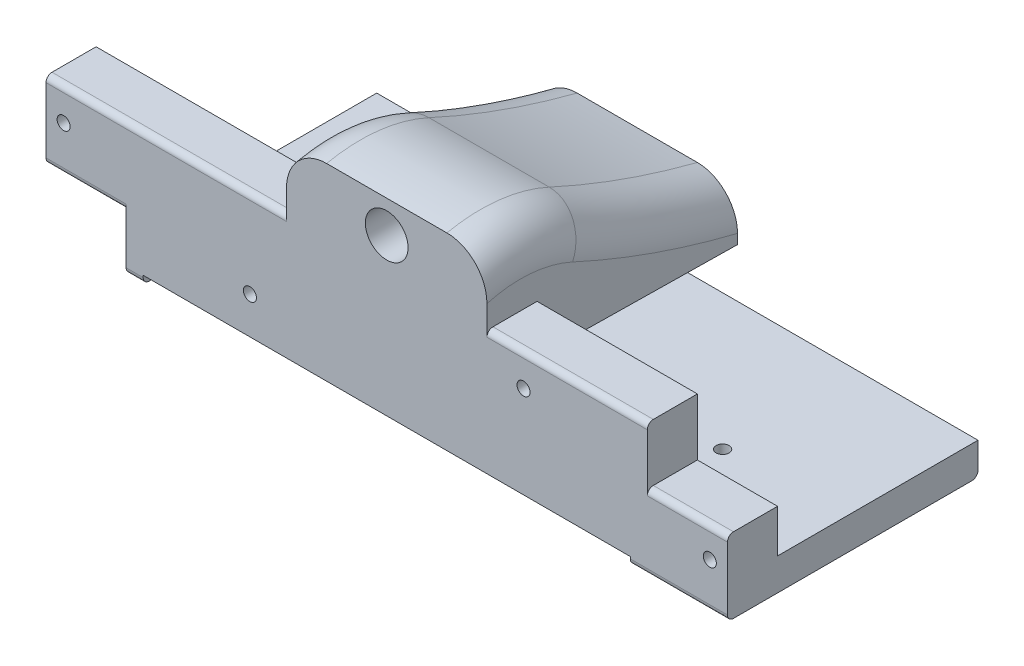
from build123d import *

# Parameters (mm, degrees)
SKETCH1_W           = 86.36
SKETCH1_H           = 31.75
BOSS_EXTRUDE1_DEPTH = 16.764
SKETCH2_W           = 25.4
SKETCH2_H           = 6.35
CUT_EXTRUDE1_DEPTH  = 86.36
SKETCH3_W           = 25.4
SKETCH3_H           = 6.35
CUT_EXTRUDE2_DEPTH  = 50.8
SKETCH5_W           = 61.722
SKETCH5_H           = 17.1196
CUT_EXTRUDE3_DEPTH  = 1.016
SKETCH5_3_R         = 0.81915
CUT_EXTRUDE4_DEPTH  = 49.964882528
CUT_EXTRUDE8_REACH  = 58.157
SKETCH6_W           = 10.16
SKETCH6_H           = 5.08
SKETCH6_R           = 0.8255
SKETCH6_H_2         = 6.985
SKETCH6_H_3         = 2.1717
SKETCH7_W           = 25.4
SKETCH7_H           = 7.62
BOSS_EXTRUDE2_DEPTH = 25.4
CUT_EXTRUDE9_DEPTH  = 25.4
FILLET1_R           = 0.381
SKETCH11_W          = 25.4
SKETCH11_H          = 8.89
BOSS_EXTRUDE5_DEPTH = 31.75
FILLET2_R           = 0.762
CUT_EXTRUDE10_DEPTH = 25.4
FILLET4_R           = 5.08
SKETCH10_R          = 2.7051
CUT_EXTRUDE11_DEPTH = 8.001


with BuildPart() as part:
    # Sketch1 → Boss-Extrude1 (new body)
    with BuildSketch(Plane(origin=(0, 0, 0), x_dir=(1, 0, 0), z_dir=(0, 1, 0))):
        Rectangle(SKETCH1_W, SKETCH1_H)
    extrude(amount=BOSS_EXTRUDE1_DEPTH)

    # Sketch2 → Cut-Extrude1 (cut)
    with BuildSketch(Plane.ZY.offset(43.18)):
        with Locations((-3.175, 7.239)):
            Rectangle(SKETCH2_W, SKETCH2_H)
    extrude(amount=-CUT_EXTRUDE1_DEPTH, mode=Mode.SUBTRACT)

    # Sketch3 → Cut-Extrude2 (cut)
    with BuildSketch(Plane.ZY.offset(43.18)):
        with Locations((-3.175, 13.589)):
            Rectangle(SKETCH3_W, SKETCH3_H)
    cut_extrude2 = extrude(amount=-CUT_EXTRUDE2_DEPTH, mode=Mode.SUBTRACT)

    # Mirror1: Cut-Extrude2 across plane
    add(cut_extrude2.mirror(Plane(origin=(0, 0, 0), x_dir=(0, 0, 1), z_dir=(1, 0, 0))), mode=Mode.SUBTRACT)

    # Sketch5 → Cut-Extrude3 (cut)
    with BuildSketch(Plane.XZ):
        with Locations((0, 7.3152)):
            Rectangle(SKETCH5_W, SKETCH5_H)
    extrude(amount=-CUT_EXTRUDE3_DEPTH, mode=Mode.SUBTRACT)

    # Sketch5_3 → Cut-Extrude4 (cut, through all)
    with BuildSketch(Plane.XZ):
        with Locations(Location((-27.9908, 1.2954, 0), (0, 0, 270))):
            Circle(SKETCH5_3_R)
        with Locations(Location((27.9908, 1.2954, 0), (0, 0, 270))):
            Circle(SKETCH5_3_R)
    extrude(amount=-CUT_EXTRUDE4_DEPTH, mode=Mode.SUBTRACT)

    # Cut-Extrude8: up to this face of the body (flat: up to its plane)
    cut_extrude8_end = Plane(part.part.faces().sort_by_distance((0, 2.032, -15.875))[0])
    # Sketch6 → Cut-Extrude8 (cut, up to the picked face)
    with BuildSketch(Plane.XY.offset(15.875), mode=Mode.PRIVATE) as cut_extrude8_sk1:
        with Locations((38.1, 12.0523)):
            Rectangle(SKETCH6_W, SKETCH6_H)
        with Locations((40.9448, 12.6873)):
            Circle(SKETCH6_R, mode=Mode.SUBTRACT)
    cut_extrude8_tool1 = split(extrude(cut_extrude8_sk1.sketch, amount=-CUT_EXTRUDE8_REACH, mode=Mode.PRIVATE), bisect_by=cut_extrude8_end, keep=Keep.BOTH, mode=Mode.PRIVATE)
    # Sketch6 → Cut-Extrude8 (cut, up to the picked face)
    with BuildSketch(Plane.XY.offset(15.875), mode=Mode.PRIVATE) as cut_extrude8_sk2:
        with Locations((40.9448, 12.6873)):
            Circle(SKETCH6_R)
    cut_extrude8_tool2 = split(extrude(cut_extrude8_sk2.sketch, amount=-CUT_EXTRUDE8_REACH, mode=Mode.PRIVATE), bisect_by=cut_extrude8_end, keep=Keep.BOTH, mode=Mode.PRIVATE)
    # Sketch6 → Cut-Extrude8 (cut, up to the picked face)
    with BuildSketch(Plane.XY.offset(15.875), mode=Mode.PRIVATE) as cut_extrude8_sk3:
        with Locations((17.3355, 12.6873)):
            Circle(SKETCH6_R)
    cut_extrude8_tool3 = split(extrude(cut_extrude8_sk3.sketch, amount=-CUT_EXTRUDE8_REACH, mode=Mode.PRIVATE), bisect_by=cut_extrude8_end, keep=Keep.BOTH, mode=Mode.PRIVATE)
    # Sketch6 → Cut-Extrude8 (cut, up to the picked face)
    with BuildSketch(Plane.XY.offset(15.875), mode=Mode.PRIVATE) as cut_extrude8_sk4:
        with Locations((40.9448, 5.715)):
            Circle(SKETCH6_R)
    cut_extrude8_tool4 = split(extrude(cut_extrude8_sk4.sketch, amount=-CUT_EXTRUDE8_REACH, mode=Mode.PRIVATE), bisect_by=cut_extrude8_end, keep=Keep.BOTH, mode=Mode.PRIVATE)
    # Sketch6 → Cut-Extrude8 (cut, up to the picked face)
    with BuildSketch(Plane.XY.offset(15.875), mode=Mode.PRIVATE) as cut_extrude8_sk5:
        with Locations((-38.1, 3.4925)):
            Rectangle(SKETCH6_W, SKETCH6_H_2)
        with Locations((-40.9448, 5.715)):
            Circle(SKETCH6_R, mode=Mode.SUBTRACT)
    cut_extrude8_tool5 = split(extrude(cut_extrude8_sk5.sketch, amount=-CUT_EXTRUDE8_REACH, mode=Mode.PRIVATE), bisect_by=cut_extrude8_end, keep=Keep.BOTH, mode=Mode.PRIVATE)
    # Sketch6 → Cut-Extrude8 (cut, up to the picked face)
    with BuildSketch(Plane.XY.offset(15.875), mode=Mode.PRIVATE) as cut_extrude8_sk6:
        with Locations((-40.9448, 5.715)):
            Circle(SKETCH6_R)
    cut_extrude8_tool6 = split(extrude(cut_extrude8_sk6.sketch, amount=-CUT_EXTRUDE8_REACH, mode=Mode.PRIVATE), bisect_by=cut_extrude8_end, keep=Keep.BOTH, mode=Mode.PRIVATE)
    # Sketch6 → Cut-Extrude8 (cut, up to the picked face)
    with BuildSketch(Plane.XY.offset(15.875), mode=Mode.PRIVATE) as cut_extrude8_sk7:
        with Locations((-17.3355, 5.715)):
            Circle(SKETCH6_R)
    cut_extrude8_tool7 = split(extrude(cut_extrude8_sk7.sketch, amount=-CUT_EXTRUDE8_REACH, mode=Mode.PRIVATE), bisect_by=cut_extrude8_end, keep=Keep.BOTH, mode=Mode.PRIVATE)
    # Sketch6 → Cut-Extrude8 (cut, up to the picked face)
    with BuildSketch(Plane.XY.offset(15.875), mode=Mode.PRIVATE) as cut_extrude8_sk8:
        with Locations((-40.9448, 12.6873)):
            Circle(SKETCH6_R)
    cut_extrude8_tool8 = split(extrude(cut_extrude8_sk8.sketch, amount=-CUT_EXTRUDE8_REACH, mode=Mode.PRIVATE), bisect_by=cut_extrude8_end, keep=Keep.BOTH, mode=Mode.PRIVATE)
    # Sketch6 → Cut-Extrude8 (cut, up to the picked face)
    with BuildSketch(Plane.XY.offset(15.875), mode=Mode.PRIVATE) as cut_extrude8_sk9:
        with Locations((38.1, 15.67815)):
            Rectangle(SKETCH6_W, SKETCH6_H_3)
    cut_extrude8_tool9 = split(extrude(cut_extrude8_sk9.sketch, amount=-CUT_EXTRUDE8_REACH, mode=Mode.PRIVATE), bisect_by=cut_extrude8_end, keep=Keep.BOTH, mode=Mode.PRIVATE)
    add(cut_extrude8_tool1.solids().sort_by(Axis((37.976895, 12.024821, 15.875), (0, 0, -1)))[0], mode=Mode.SUBTRACT)
    add(cut_extrude8_tool2.solids().sort_by(Axis((40.9448, 12.6873, 15.875), (0, 0, -1)))[0], mode=Mode.SUBTRACT)
    add(cut_extrude8_tool3.solids().sort_by(Axis((17.3355, 12.6873, 15.875), (0, 0, -1)))[0], mode=Mode.SUBTRACT)
    add(cut_extrude8_tool4.solids().sort_by(Axis((40.9448, 5.715, 15.875), (0, 0, -1)))[0], mode=Mode.SUBTRACT)
    add(cut_extrude8_tool5.solids().sort_by(Axis((-38.011513, 3.42337, 15.875), (0, 0, -1)))[0], mode=Mode.SUBTRACT)
    add(cut_extrude8_tool6.solids().sort_by(Axis((-40.9448, 5.715, 15.875), (0, 0, -1)))[0], mode=Mode.SUBTRACT)
    add(cut_extrude8_tool7.solids().sort_by(Axis((-17.3355, 5.715, 15.875), (0, 0, -1)))[0], mode=Mode.SUBTRACT)
    add(cut_extrude8_tool8.solids().sort_by(Axis((-40.9448, 12.6873, 15.875), (0, 0, -1)))[0], mode=Mode.SUBTRACT)
    add(cut_extrude8_tool9.solids().sort_by(Axis((38.1, 15.67815, 15.875), (0, 0, -1)))[0], mode=Mode.SUBTRACT)

    # Sketch7 → Boss-Extrude2 (add)
    with BuildSketch(Plane(origin=(0, 0, 9.525), x_dir=(-1, 0, 0), z_dir=(0, 0, -1))):
        with Locations((0, 12.954)):
            Rectangle(SKETCH7_W, SKETCH7_H)
    extrude(amount=BOSS_EXTRUDE2_DEPTH)

    # Sketch8 → Cut-Extrude9 (cut)
    with BuildSketch(Plane.ZY.offset(12.7)):
        Polygon((-15.875, 10.287), (9.525, 10.668), (9.525, 9.144), (-15.875, 9.144), align=None)
    extrude(amount=-CUT_EXTRUDE9_DEPTH, mode=Mode.SUBTRACT)

    # Fillet1
    fillet1_edges = [part.edges().sort_by_distance(p)[0] for p in [
        (0, 10.668, 9.525),
    ]]
    fillet(fillet1_edges, radius=FILLET1_R)

    # Sketch11 → Boss-Extrude5 (add)
    with BuildSketch(Plane.XY.offset(15.875)):
        with Locations((0, 21.209)):
            Rectangle(SKETCH11_W, SKETCH11_H)
    extrude(amount=-BOSS_EXTRUDE5_DEPTH)

    # Fillet2
    fillet2_edges = [part.edges().sort_by_distance(p)[0] for p in [
        (-31.9405, 0, 15.875),
        (-38.1, 6.985, 15.875),
        (38.1, 9.5123, 15.875),
        (-27.94, 16.764, 15.875),
        (22.86, 16.764, 15.875),
        (5.08, 0, -15.875),
        (37.0205, 0, 15.875),
    ]]
    fillet(fillet2_edges, radius=FILLET2_R)

    # Sketch12 → Cut-Extrude10 (cut)
    with BuildSketch(Plane.ZY.offset(12.7)):
        with BuildLine():
            Line((-15.875, 16.764), (-15.875, 25.654))
            Line((-15.875, 25.654), (15.875, 25.654))
            Line((15.875, 25.654), (15.875, 24.911939438))
            ThreePointArc((15.875, 24.911939438), (9.270292434, 25.222373256), (2.900847527, 23.447914815))
            ThreePointArc((2.900847527, 23.447914815), (-6.338198623, 19.687743912), (-15.875, 16.764))
        make_face()
    extrude(amount=-CUT_EXTRUDE10_DEPTH, mode=Mode.SUBTRACT)

    # Fillet4
    fillet4_edges = [part.edges().sort_by_distance(p)[0] for p in [
        (-12.7, 19.687743912, -6.338198623),
        (-12.7, 25.222373256, 9.270292434),
        (12.7, 19.687743912, -6.338198623),
        (12.7, 25.222373256, 9.270292434),
    ]]
    fillet(fillet4_edges, radius=FILLET4_R)

    # Sketch10 → Cut-Extrude11 (cut)
    with BuildSketch(Plane.XY.offset(15.875)):
        with Locations((0, 20.828)):
            Circle(SKETCH10_R)
    extrude(amount=-CUT_EXTRUDE11_DEPTH, mode=Mode.SUBTRACT)


solid = part.part
